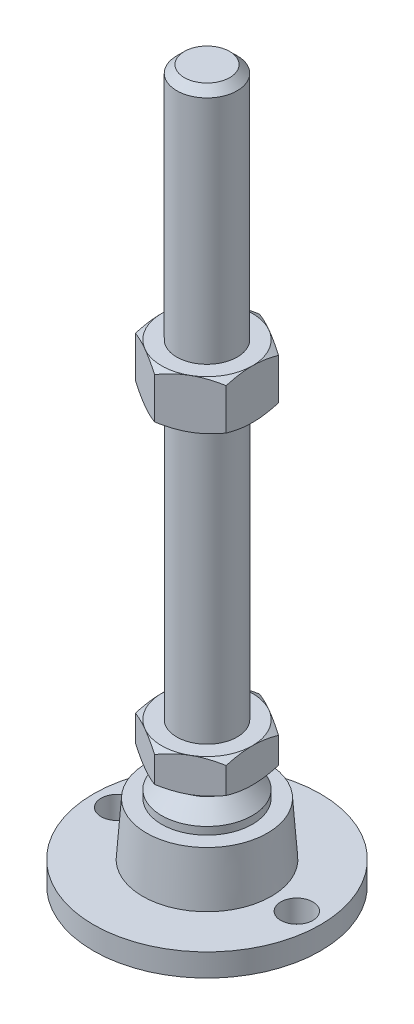
from build123d import *

# Parameters (mm, degrees)
EXTRUDE_1_DEPTH     = 9
EXTRUDE_2_DEPTH     = 13
SKETCH_5_R          = 4.25
CUT_EXTRUDE_1_DEPTH = 7


with BuildPart() as part:
    # Эскиз1 → Повернуть1 (revolve)
    with BuildSketch(Plane.XY, mode=Mode.PRIVATE) as revolve_1_sk:
        Polygon((0, 0), (-30, 0), (-30, 6), (-17, 6), (-16, 20), (-12, 20), (-12, 22), (-8, 26), (-8, 29), (-8, 38), (-8, 186), (-6, 188), (0, 188), align=None)
    revolve(revolve_1_sk.sketch.rotate(Axis((0, 0, 0), (0, 1, 0)), 180), axis=Axis((0, 0, 0), (0, 1, 0)))  # turned: the seam where the file's is

    # Эскиз2 → Бобышка-Вытянуть1 (add)
    with BuildSketch(Plane(origin=(0, 29, 0), x_dir=(1, 0, 0), z_dir=(0, 1, 0))):
        Polygon((0, 13.856406461), (-12, 6.92820323), (-12, -6.92820323), (0, -13.856406461), (12, -6.92820323), (12, 6.92820323), align=None)
    extrude(amount=EXTRUDE_1_DEPTH)

    # Эскиз3 → Бобышка-Вытянуть2 (add)
    with BuildSketch(Plane(origin=(0, 112, 0), x_dir=(1, 0, 0), z_dir=(0, 1, 0))):
        Polygon((12, 6.92820323), (0, 13.856406461), (-12, 6.92820323), (-12, -6.92820323), (0, -13.856406461), (12, -6.92820323), align=None)
    extrude(amount=EXTRUDE_2_DEPTH)

    # Эскиз4 → Вырез-Повернуть2 (revolve, cut)
    with BuildSketch(Plane.XY, mode=Mode.PRIVATE) as cut_revolve_2_sk:
        Polygon((-23.258330249, 125), (-12, 125), (-23.258330249, 118.5), align=None)
        Polygon((-23.258330249, 112), (-23.258330249, 118.5), (-12, 112), align=None)
        Polygon((-19.794228634, 38), (-19.794228634, 33.5), (-12, 38), align=None)
        Polygon((-19.794228634, 33.5), (-19.794228634, 29), (-12, 29), align=None)
    revolve(cut_revolve_2_sk.sketch.rotate(Axis((0, 188, 0), (0, -1, 0)), 180), axis=Axis((0, 188, 0), (0, -1, 0)), mode=Mode.SUBTRACT)  # turned: the seam where the file's is

    # Эскиз5 → Вырез-Вытянуть1 (cut, through all)
    with BuildSketch(Plane(origin=(0, 6, 0), x_dir=(1, 0, 0), z_dir=(0, 1, 0))):
        with Locations(Location((-23.75, 0, 0), (0, 0, 180))):  # turned: the seam where the file's is
            Circle(SKETCH_5_R)
        with Locations(Location((23.75, 0, 0), (0, 0, 180))):  # turned: the seam where the file's is
            Circle(SKETCH_5_R)
    extrude(amount=-CUT_EXTRUDE_1_DEPTH, mode=Mode.SUBTRACT)


solid = part.part
